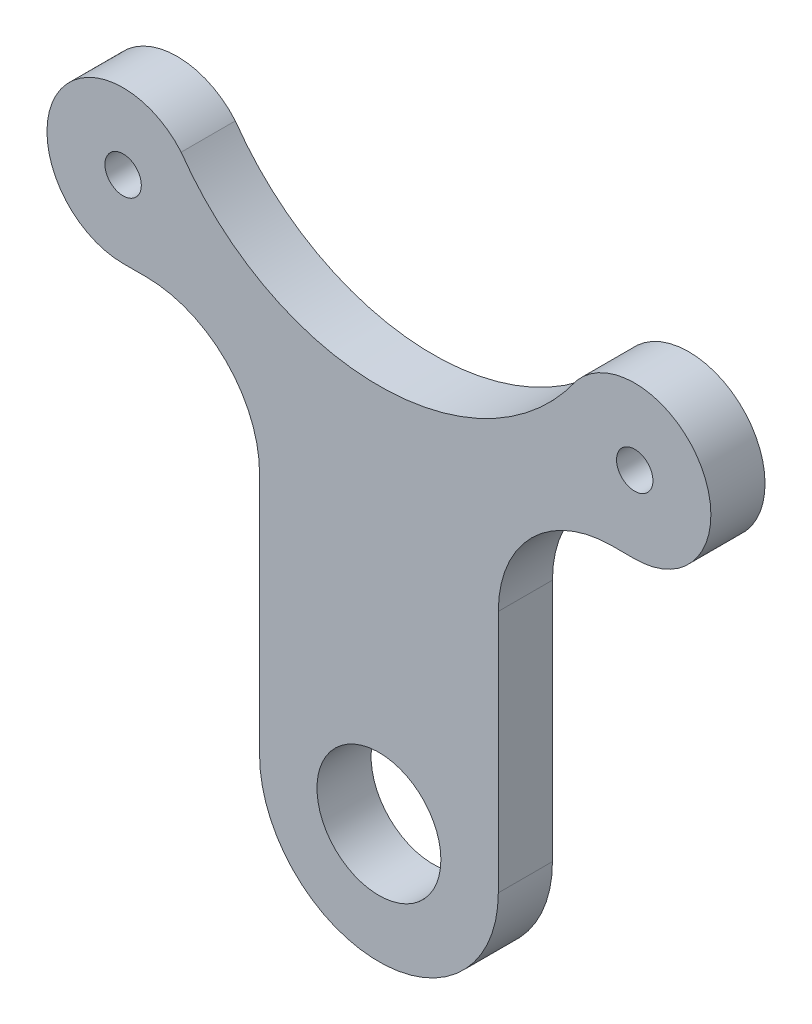
from build123d import *

# Parameters (mm, degrees)
SKETCH1_R            = 5.44942
BOSS_EXTRUDE1_DEPTH  = 4.763
M3_CLEARANCE_HOLE1_D = 3.2


with BuildPart() as part:
    # Sketch1 → Boss-Extrude1 (new body)
    with BuildSketch(Plane.XY):
        with BuildLine():
            ThreePointArc((10.5, 21.439339413), (13.428932188, 28.510407225), (20.5, 31.439339413))
            Line((20.5, 31.439339413), (22.5, 31.439339413))
            ThreePointArc((22.5, 31.439339413), (28.581287214, 40.95144642), (17.395155109, 42.478758572))
            ThreePointArc((17.395155109, 42.478758572), (17.105956053, 42.072123099), (16.807253326, 41.672416728))
            ThreePointArc((16.807253326, 41.672416728), (0, 33.374189215), (-16.807253326, 41.672416728))
            ThreePointArc((-16.807253326, 41.672416728), (-17.105956053, 42.072123099), (-17.395155109, 42.478758572))
            ThreePointArc((-17.395155109, 42.478758572), (-28.581287214, 40.95144642), (-22.5, 31.439339413))
            Line((-22.5, 31.439339413), (-20.5, 31.439339413))
            ThreePointArc((-20.5, 31.439339413), (-13.428932188, 28.510407225), (-10.5, 21.439339413))
            Line((-10.5, 21.439339413), (-10.5, 0))
            ThreePointArc((-10.5, 0), (0, -10.5), (10.5, 0))
            Line((10.5, 0), (10.5, 21.439339413))
        make_face()
        Circle(SKETCH1_R, mode=Mode.SUBTRACT)
    extrude(amount=BOSS_EXTRUDE1_DEPTH)

    # M3 Clearance Hole1 (through all)
    with Locations(Plane.XY.offset(4.763)):
        with Locations((-22.5, 38.195891618), (22.5, 38.195891618)):
            Hole(M3_CLEARANCE_HOLE1_D / 2)


solid = part.part
